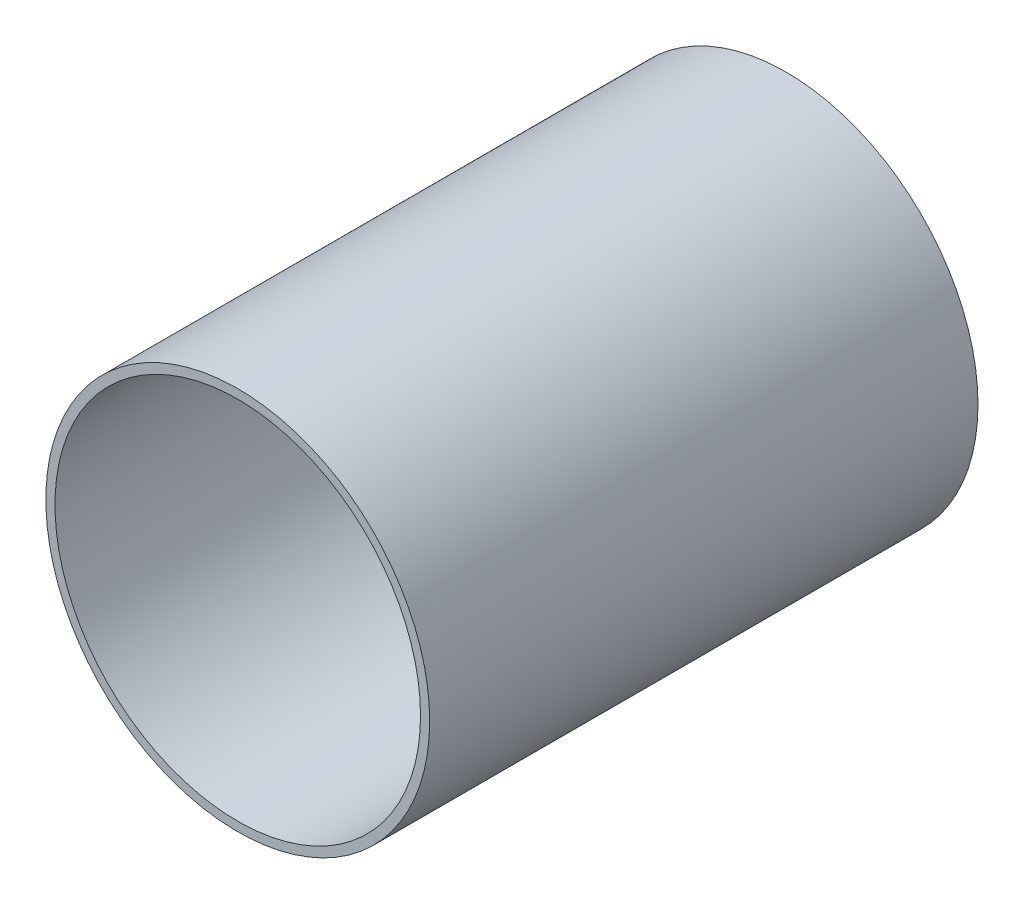
from build123d import *

# Parameters (mm, degrees)
SKETCH1_R           = 53.34
SKETCH1_R_2         = 50.8
BOSS_EXTRUDE1_DEPTH = 152.4


with BuildPart() as part:
    # Sketch1 → Boss-Extrude1 (new body)
    with BuildSketch(Plane.XY):
        Circle(SKETCH1_R)
        Circle(SKETCH1_R_2, mode=Mode.SUBTRACT)
    extrude(amount=BOSS_EXTRUDE1_DEPTH)


solid = part.part
